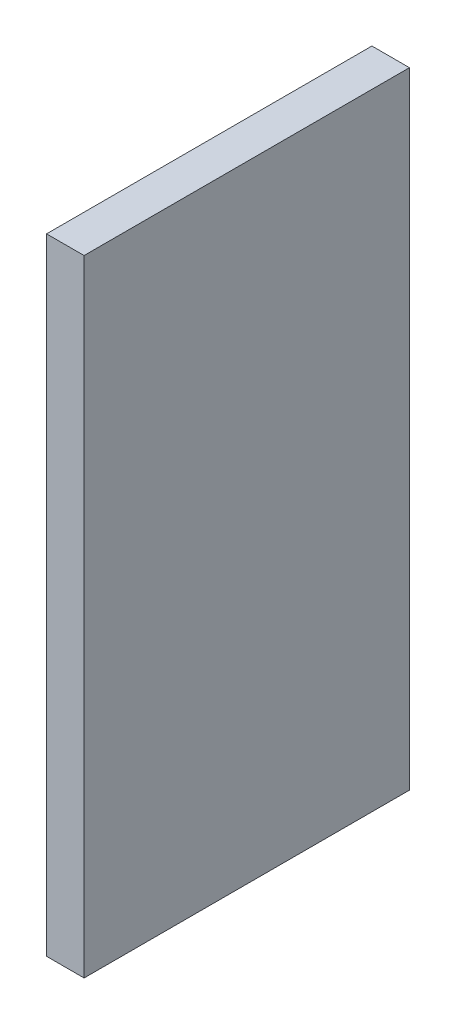
from build123d import *

# Parameters (mm, degrees)
CROQUIS1_W              = 26
CROQUIS1_H              = 50
SALIENTE_EXTRUIR1_DEPTH = 3


with BuildPart() as part:
    # Croquis1 → Saliente-Extruir1 (new body)
    with BuildSketch(Plane(origin=(0, 0, 0), x_dir=(0, 0, -1), z_dir=(1, 0, 0))):
        with Locations((-13, 25)):
            Rectangle(CROQUIS1_W, CROQUIS1_H)
    extrude(amount=SALIENTE_EXTRUIR1_DEPTH)


solid = part.part
